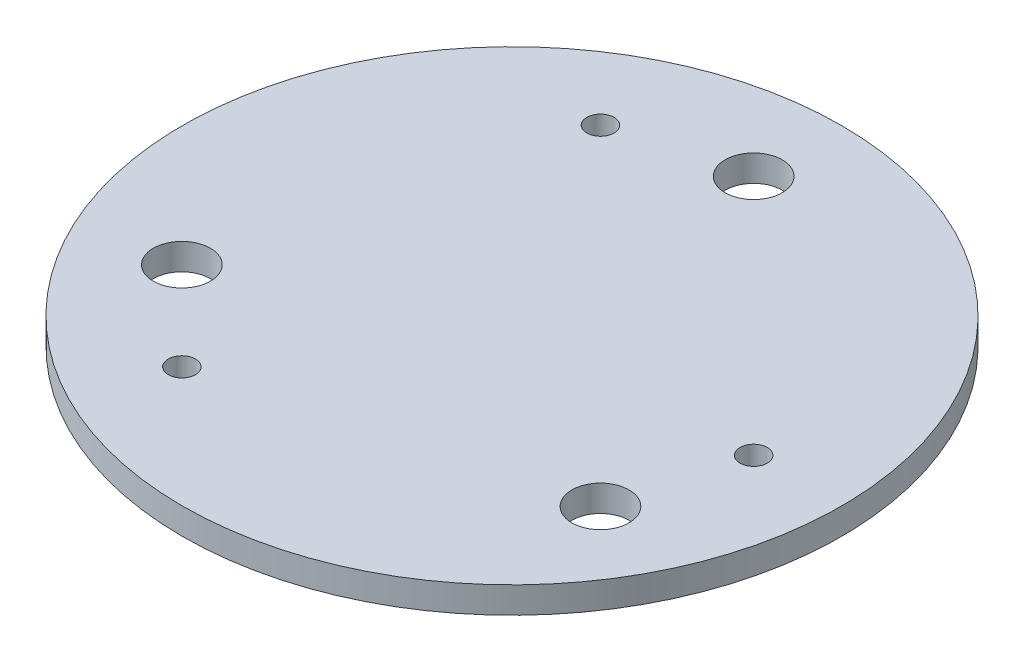
from build123d import *

# Parameters (mm, degrees)
SKETCH1_R           = 75
SKETCH1_R_2         = 6.5
SKETCH1_R_3         = 3.1
BOSS_EXTRUDE1_DEPTH = 6


with BuildPart() as part:
    # Sketch1 → Boss-Extrude1 (new body)
    with BuildSketch(Plane(origin=(0, 0, 0), x_dir=(1, 0, 0), z_dir=(0, 1, 0))):
        Circle(SKETCH1_R)
        with Locations((0, 55)):
            Circle(SKETCH1_R_2, mode=Mode.SUBTRACT)
        with Locations((-47.631397208, -27.5)):
            Circle(SKETCH1_R_2, mode=Mode.SUBTRACT)
        with Locations((47.631397208, -27.5)):
            Circle(SKETCH1_R_2, mode=Mode.SUBTRACT)
        with Locations((-27.5, 47.631397208)):
            Circle(SKETCH1_R_3, mode=Mode.SUBTRACT)
        with Locations((55, 0)):
            Circle(SKETCH1_R_3, mode=Mode.SUBTRACT)
        with Locations((-27.5, -47.631397208)):
            Circle(SKETCH1_R_3, mode=Mode.SUBTRACT)
    extrude(amount=BOSS_EXTRUDE1_DEPTH)


solid = part.part
